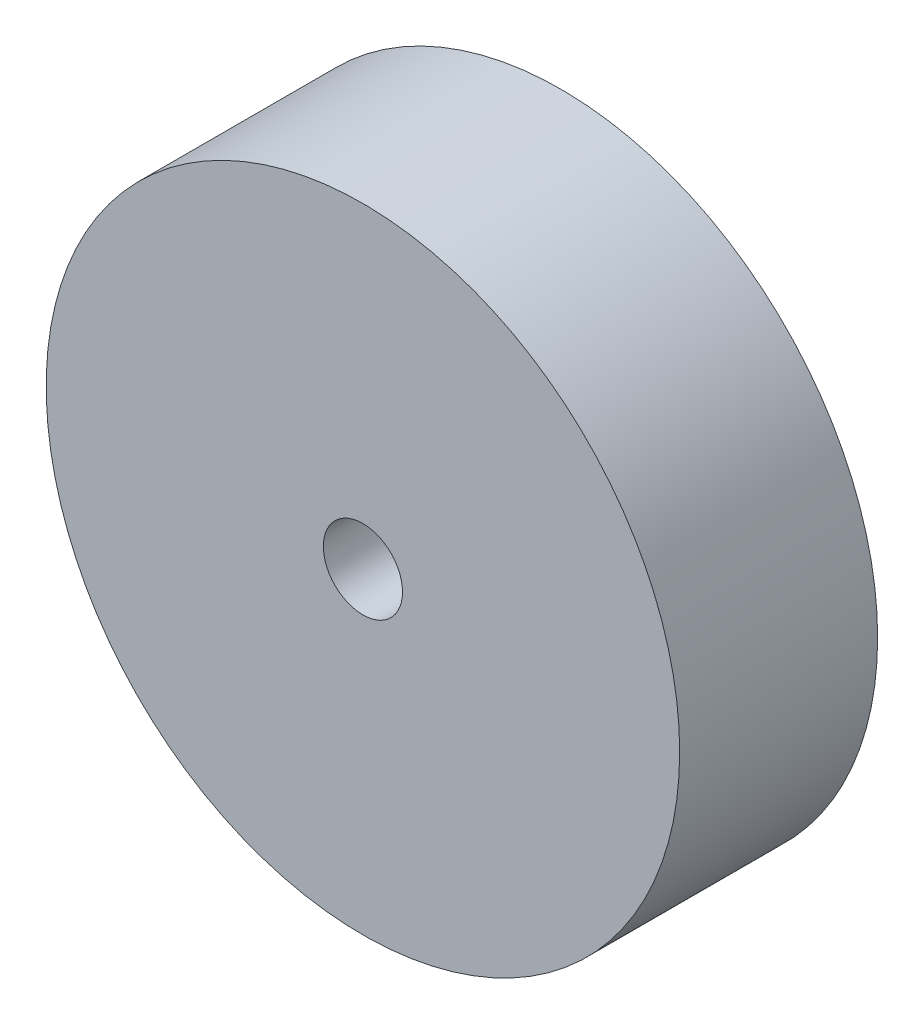
from build123d import *

# Parameters (mm, degrees)
SKETCH1_R           = 50.8
SKETCH1_R_2         = 6.35
BOSS_EXTRUDE1_DEPTH = 31.75


with BuildPart() as part:
    # Sketch1 → Boss-Extrude1 (new body)
    with BuildSketch(Plane.XY):
        Circle(SKETCH1_R)
        Circle(SKETCH1_R_2, mode=Mode.SUBTRACT)
    extrude(amount=BOSS_EXTRUDE1_DEPTH)


solid = part.part
